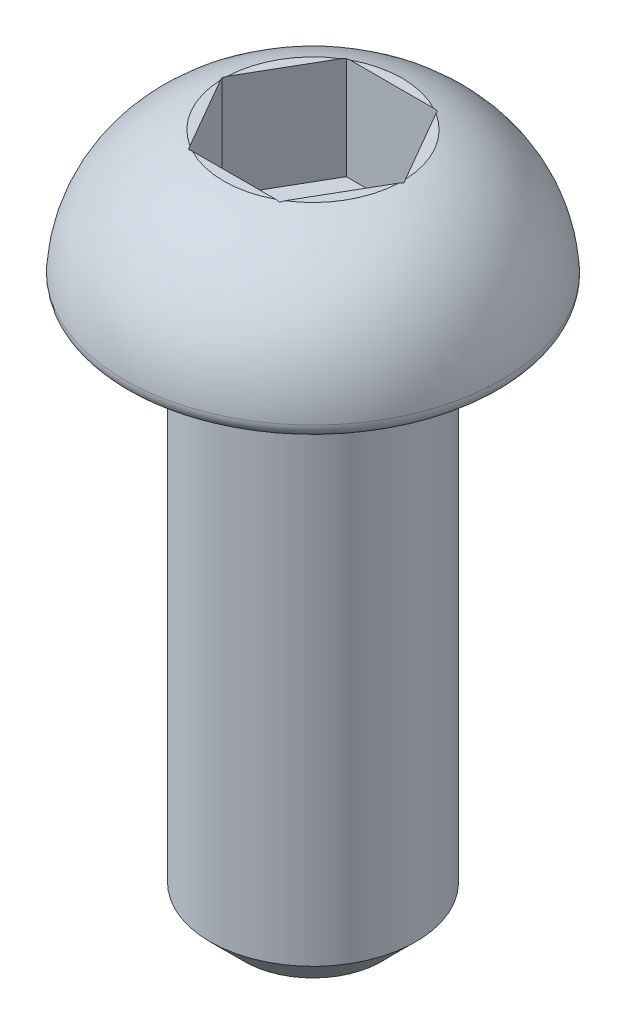
from build123d import *

# Parameters (mm, degrees)
FILLET_1_R          = 0.2
CUT_EXTRUDE_1_DEPTH = 1.5
SKETCH_3_R          = 1.5
EXTRUDE_1_DEPTH     = 8
CHAMFER_1_SIZE      = 0.5


with BuildPart() as part:
    # 草图1 → 旋转1 (revolve)
    with BuildSketch(Plane.XY):
        with BuildLine():
            Line((0, 0), (0, 2))
            Line((0, 2), (1.3, 2))
            ThreePointArc((1.3, 2), (2.370691821, 1.250626571), (2.75, 0))
            Line((2.75, 0), (0, 0))
        make_face()
    revolve(axis=Axis((0, 0, 0), (0, 1, 0)))

    # 圆角1
    fillet_1_edges = [part.edges().sort_by_distance(p)[0] for p in [
        (-2.75, 0, 0),
    ]]
    fillet(fillet_1_edges, radius=FILLET_1_R)

    # 草图2 → 切除-拉伸1 (cut)
    with BuildSketch(Plane(origin=(0, 2, 0), x_dir=(1, 0, 0), z_dir=(0, 1, 0))):
        Polygon((1.327905619, 0), (0.66395281, 1.15), (-0.66395281, 1.15), (-1.327905619, 0), (-0.66395281, -1.15), (0.66395281, -1.15), align=None)
    extrude(amount=-CUT_EXTRUDE_1_DEPTH, mode=Mode.SUBTRACT)

    # 草图3 → 凸台-拉伸1 (add)
    with BuildSketch(Plane.XZ):
        Circle(SKETCH_3_R)
    extrude(amount=EXTRUDE_1_DEPTH)

    # 倒角1
    chamfer_1_edges = [part.edges().sort_by_distance(p)[0] for p in [
        (-1.5, -8, 0),
    ]]
    chamfer(chamfer_1_edges, length=CHAMFER_1_SIZE)


solid = part.part
